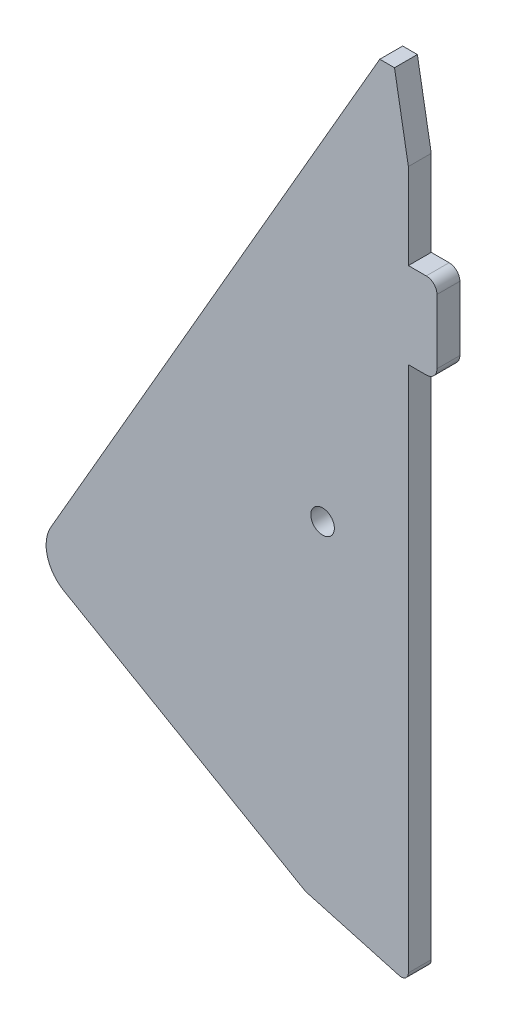
from build123d import *

# Parameters (mm, degrees)
SKETCH1_R           = 1.65
BOSS_EXTRUDE1_DEPTH = 3.2
SKETCH2_W           = 4
SKETCH2_H           = 12
BOSS_EXTRUDE2_DEPTH = 3.2
FILLET1_R           = 1.5


with BuildPart() as part:
    # Sketch1 → Boss-Extrude1 (new body)
    with BuildSketch(Plane.XY):
        with BuildLine():
            Line((1.830127019, -31.504464167), (35.605117766, -51.004464167))
            Line((35.605117766, -51.004464167), (48.732545217, -54.648197122))
            ThreePointArc((48.732545217, -54.648197122), (49.6052046, -54.480696676), (50, -53.68462671))
            Line((50, -53.68462671), (50, 44))
            Line((50, 44), (48.060403212, 55))
            Line((48.060403212, 55), (46, 55))
            Line((46, 55), (0, -24.674337148))
            ThreePointArc((0, -24.674337148), (-0.499502113, -28.468432374), (1.830127019, -31.504464167))
        make_face()
        with Locations((38, -5)):
            Circle(SKETCH1_R, mode=Mode.SUBTRACT)
    extrude(amount=BOSS_EXTRUDE1_DEPTH)

    # Sketch2 → Boss-Extrude2 (add)
    with BuildSketch(Plane.XY.offset(3.2)):
        with Locations((52, 26)):
            Rectangle(SKETCH2_W, SKETCH2_H)
    extrude(amount=-BOSS_EXTRUDE2_DEPTH)

    # Fillet1
    fillet1_edges = [part.edges().sort_by_distance(p)[0] for p in [
        (54, 32, 1.6),
        (54, 20, 1.6),
    ]]
    fillet(fillet1_edges, radius=FILLET1_R)


solid = part.part
